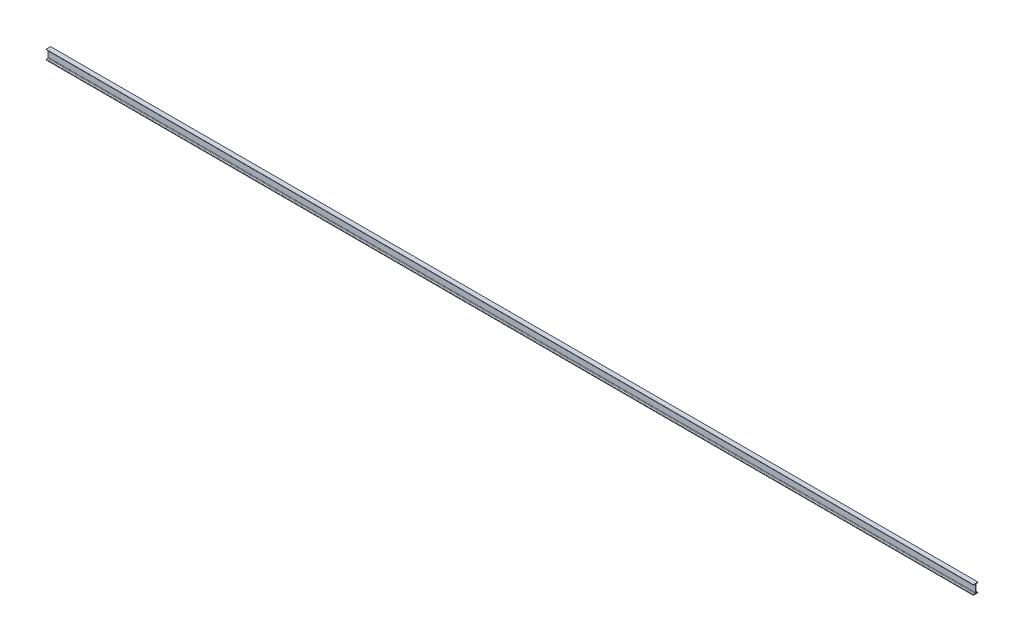
from build123d import *

# Parameters (mm, degrees)
SB_BEAM_120_X_12_2_DEPTH = 12000


with BuildPart() as part:
    # Sketch12 → Sb beam 120 X 12(2) (new body)
    with BuildSketch(Plane(origin=(0, 0, 0), x_dir=(0, 0, 1), z_dir=(1, 0, 0))):
        with BuildLine():
            Line((-30, -60), (-30, -58.080070835))
            ThreePointArc((-30, -58.080070835), (-29.052095223, -55.494589303), (-26.657642624, -54.134502919))
            Line((-26.657642624, -54.134502919), (-9.184714752, -51.222135832))
            ThreePointArc((-9.184714752, -51.222135832), (-4.395809555, -48.501963064), (-2.5, -43.331))
            Line((-2.5, -43.331), (-2.5, 43.331))
            ThreePointArc((-2.5, 43.331), (-4.395809555, 48.501963064), (-9.184714752, 51.222135832))
            Line((-9.184714752, 51.222135832), (-26.657642624, 54.134502919))
            ThreePointArc((-26.657642624, 54.134502919), (-29.052095223, 55.494589303), (-30, 58.080070835))
            Line((-30, 58.080070835), (-30, 60))
            Line((-30, 60), (30, 60))
            Line((30, 60), (30, 58.080070835))
            ThreePointArc((30, 58.080070835), (29.052095223, 55.494589303), (26.657642624, 54.134502919))
            Line((26.657642624, 54.134502919), (9.184714752, 51.222135832))
            ThreePointArc((9.184714752, 51.222135832), (4.395809555, 48.501963064), (2.5, 43.331))
            Line((2.5, 43.331), (2.5, -43.331))
            ThreePointArc((2.5, -43.331), (4.395809555, -48.501963064), (9.184714752, -51.222135832))
            Line((9.184714752, -51.222135832), (26.657642624, -54.134502919))
            ThreePointArc((26.657642624, -54.134502919), (29.052095223, -55.494589303), (30, -58.080070835))
            Line((30, -58.080070835), (30, -60))
            Line((30, -60), (-30, -60))
        make_face()
    extrude(amount=SB_BEAM_120_X_12_2_DEPTH)


solid = part.part
